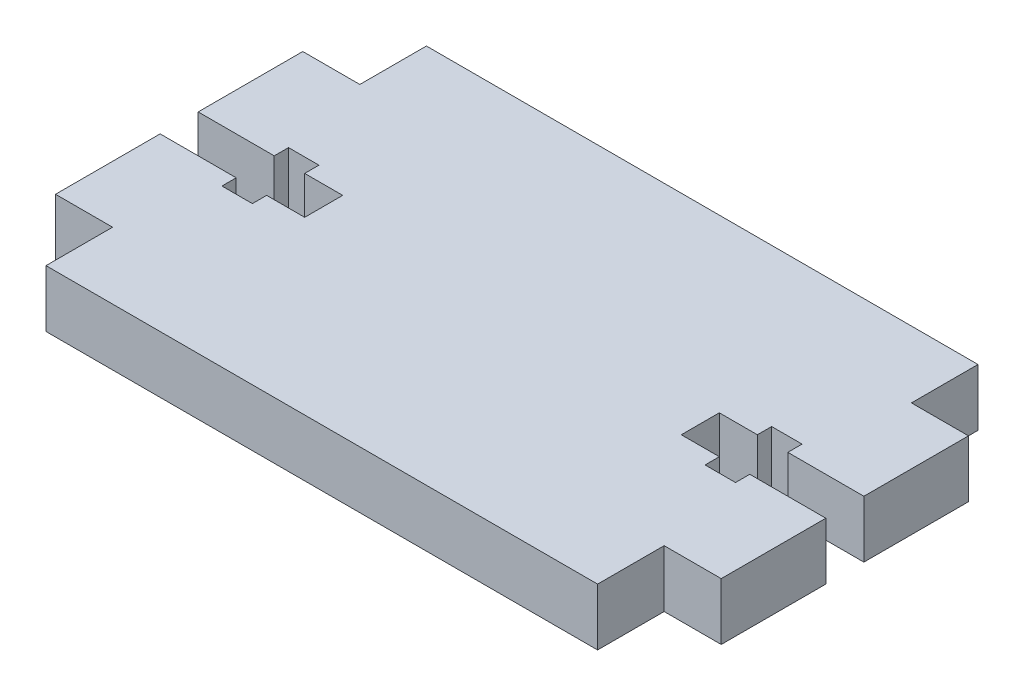
from build123d import *

# Parameters (mm, degrees)
BOSS_EXTRUDE1_DEPTH = 6


with BuildPart() as part:
    # Sketch1 → Boss-Extrude1 (new body)
    with BuildSketch(Plane(origin=(0, 0, 0), x_dir=(1, 0, 0), z_dir=(0, 1, 0))):
        Polygon((-29, 20), (29, 20), (29, 13), (35, 13), (35, 2), (27, 2), (27, 3.5), (23.8, 3.5), (23.8, 2), (19.8, 2), (19.8, -2), (23.8, -2), (23.8, -3.5), (27, -3.5), (27, -2), (35, -2), (35, -13), (29, -13), (29, -20), (-29, -20), (-29, -13), (-35, -13), (-35, -2), (-27, -2), (-27, -3.5), (-23.8, -3.5), (-23.8, -2), (-19.8, -2), (-19.8, 2), (-23.8, 2), (-23.8, 3.5), (-27, 3.5), (-27, 2), (-35, 2), (-35, 13), (-29, 13), align=None)
    extrude(amount=BOSS_EXTRUDE1_DEPTH)


solid = part.part
